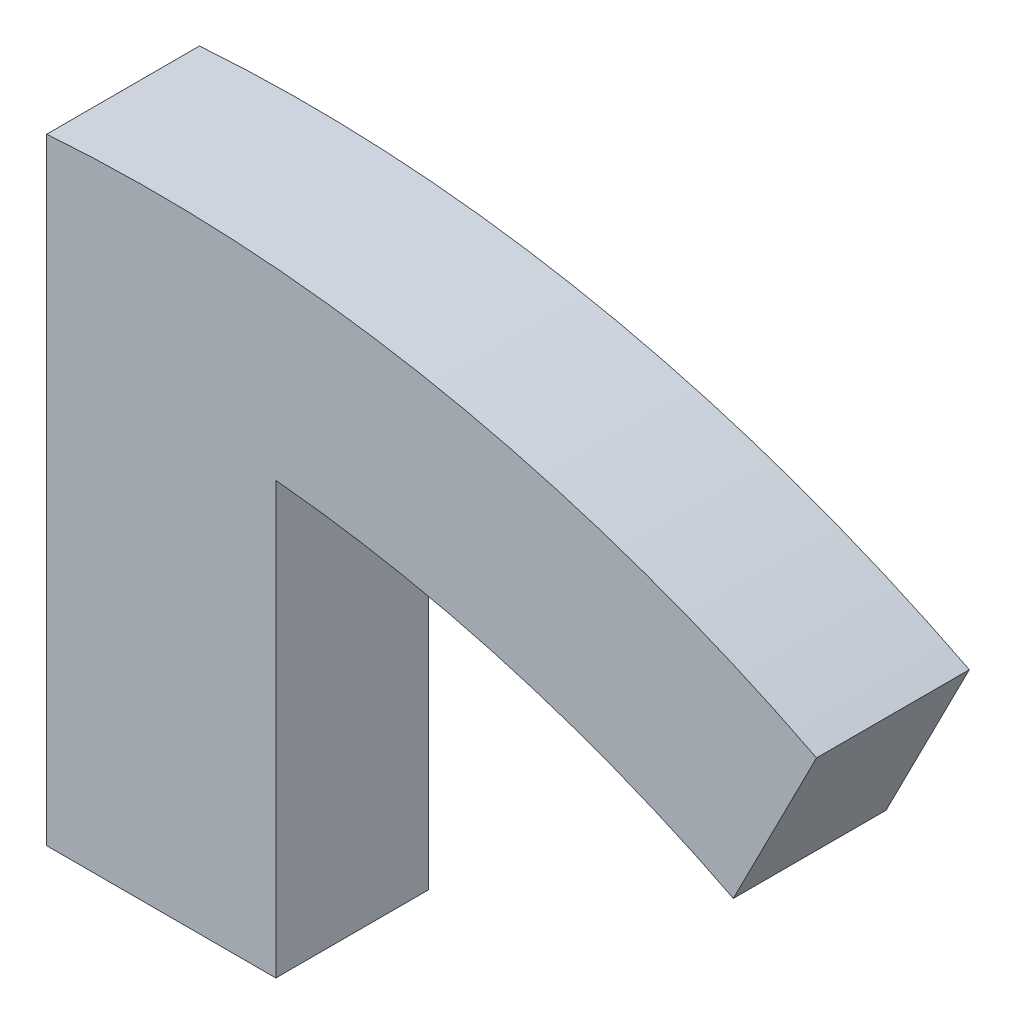
from build123d import *

# Parameters (mm, degrees)
BOSS_EXTRUDE1_DEPTH = 5


with BuildPart() as part:
    # Sketch1 → Boss-Extrude1 (new body, symmetric)
    with BuildSketch(Plane.XY):
        with BuildLine():
            Line((37.953605778, 74.488145422), (43.401491775, 85.180223712))
            ThreePointArc((43.401491775, 85.180223712), (18.896814133, 93.713768549), (-7, 95.343379424))
            Line((-7, 95.343379424), (-7, 55))
            Line((-7, 55), (0, 55))
            Line((0, 55), (8, 55))
            Line((8, 55), (8, 83.216344548))
            ThreePointArc((8, 83.216344548), (23.387578669, 80.261953403), (37.953605778, 74.488145422))
        make_face()
    extrude(amount=BOSS_EXTRUDE1_DEPTH, both=True)


solid = part.part
